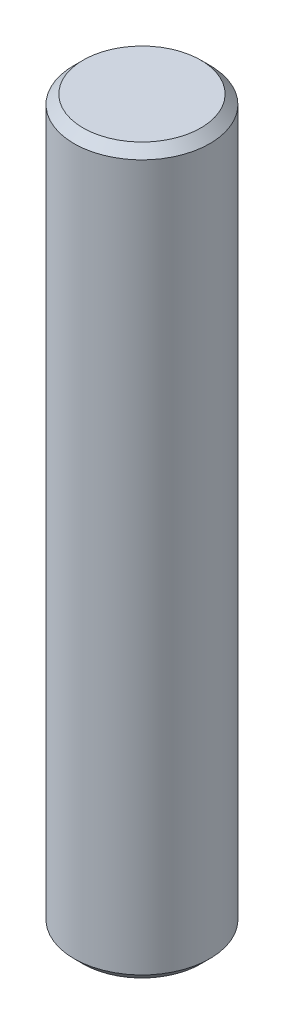
from build123d import *

# Parameters (mm, degrees)
SKETCH_1_R      = 1.5
EXTRUDE_1_DEPTH = 16
CHAMFER_1_SIZE  = 0.2


with BuildPart() as part:
    # 草图1 → 凸台-拉伸1 (new body)
    with BuildSketch(Plane(origin=(0, 0, 0), x_dir=(1, 0, 0), z_dir=(0, 1, 0))):
        Circle(SKETCH_1_R)
    extrude(amount=EXTRUDE_1_DEPTH)

    # 倒角1
    chamfer_1_edges = [part.edges().sort_by_distance(p)[0] for p in [
        (-1.5, 0, 0),
        (-1.5, 16, 0),
    ]]
    chamfer(chamfer_1_edges, length=CHAMFER_1_SIZE)


solid = part.part
